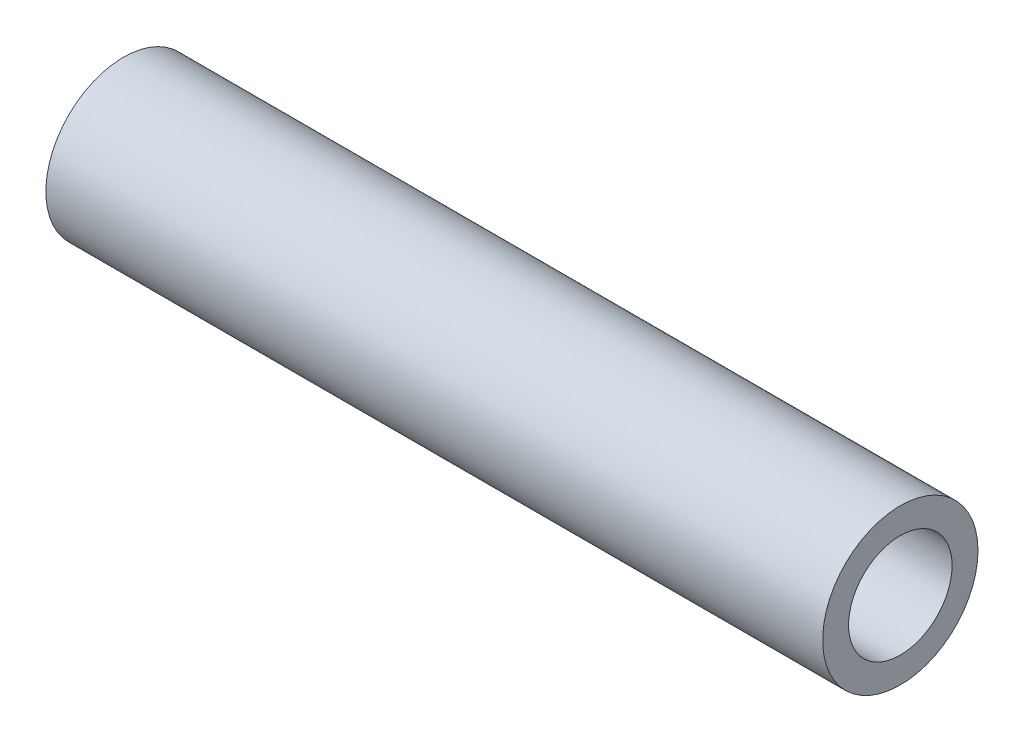
from build123d import *

# Parameters (mm, degrees)
SKETCH1_R           = 30
BOSS_EXTRUDE1_DEPTH = 300
SKETCH2_R           = 20
CUT_EXTRUDE1_DEPTH  = 300


with BuildPart() as part:
    # Sketch1 → Boss-Extrude1 (new body)
    with BuildSketch(Plane(origin=(0, 0, 0), x_dir=(0, 0, -1), z_dir=(1, 0, 0))):
        Circle(SKETCH1_R)
    extrude(amount=BOSS_EXTRUDE1_DEPTH)

    # Sketch2 → Cut-Extrude1 (cut)
    with BuildSketch(Plane(origin=(300, 0, 0), x_dir=(0, 0, -1), z_dir=(1, 0, 0))):
        Circle(SKETCH2_R)
    extrude(amount=-CUT_EXTRUDE1_DEPTH, mode=Mode.SUBTRACT)


solid = part.part
